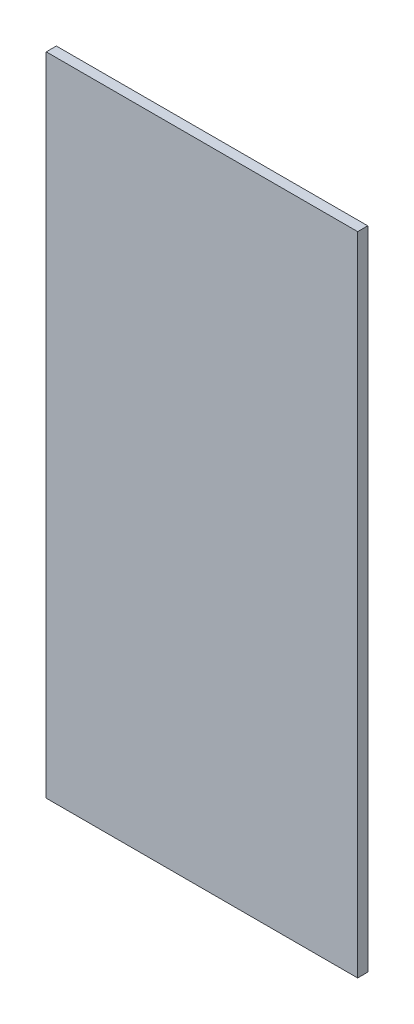
from build123d import *

# Parameters (mm, degrees)
ESBO_O1_W                = 185
ESBO_O1_H                = 384
RESSALTO_EXTRUS_O1_DEPTH = 6


with BuildPart() as part:
    # Esboço1 → Ressalto-extrusão1 (new body)
    with BuildSketch(Plane.XY):
        Rectangle(ESBO_O1_W, ESBO_O1_H)
    extrude(amount=RESSALTO_EXTRUS_O1_DEPTH)


solid = part.part
